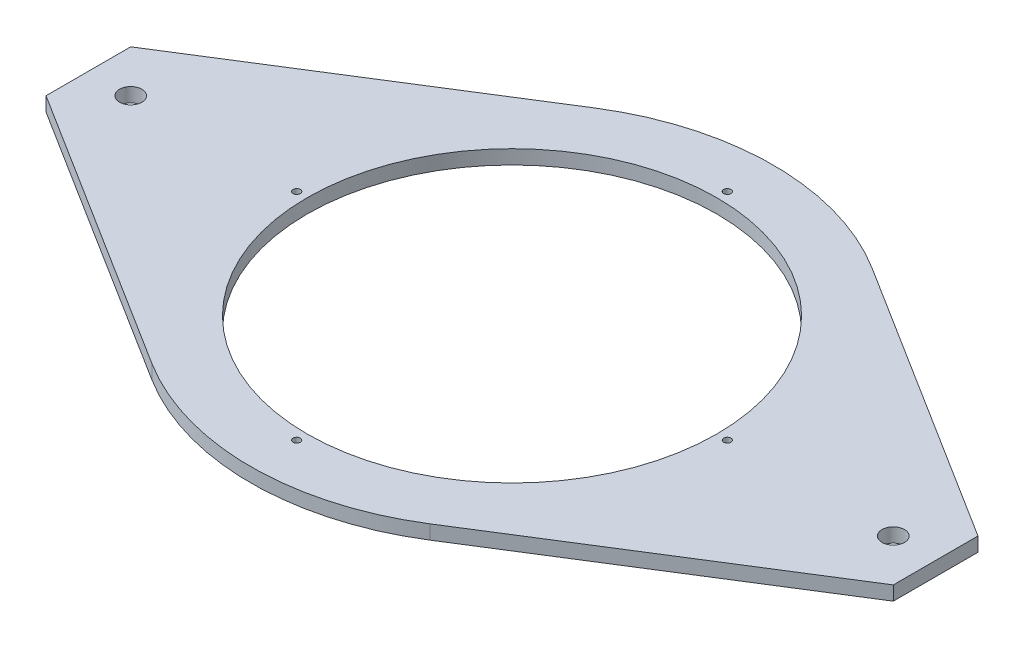
from build123d import *

# Parameters (mm, degrees)
SKETCH1_R               = 92.075
BOSS_EXTRUDE1_DEPTH     = 6.35
F_4_CLEARANCE_HOLE1_D   = 3.2639
F_3_8_CLEARANCE_HOLE1_D = 10.0838


with BuildPart() as part:
    # Sketch1 → Boss-Extrude1 (new body)
    with BuildSketch(Plane(origin=(0, 0, 0), x_dir=(1, 0, 0), z_dir=(0, 1, 0))):
        with BuildLine():
            Line((-190.5, 19.05), (-190.5, -19.05))
            Line((-190.5, -19.05), (-62.495726193, -99.47190474))
            ThreePointArc((-62.495726193, -99.47190474), (0, -117.475), (62.495726193, -99.47190474))
            Line((62.495726193, -99.47190474), (190.5, -19.05))
            Line((190.5, -19.05), (190.5, 19.05))
            Line((190.5, 19.05), (62.495726193, 99.47190474))
            ThreePointArc((62.495726193, 99.47190474), (0, 117.475), (-62.495726193, 99.47190474))
            Line((-62.495726193, 99.47190474), (-190.5, 19.05))
        make_face()
        with Locations(Location((0, 0, 0), (0, 0, 270))):  # turned: the seam where the file's is
            Circle(SKETCH1_R, mode=Mode.SUBTRACT)
    extrude(amount=BOSS_EXTRUDE1_DEPTH)

    # #4 Clearance Hole1 (through all)
    with Locations(Plane(origin=(0, 6.35, 0), x_dir=(1, 0, 0), z_dir=(0, 1, 0))):
        with Locations((0, 96.8375), (96.8375, 0), (0, -96.8375), (-96.8375, 0)):
            Hole(F_4_CLEARANCE_HOLE1_D / 2)

    # 3/8 Clearance Hole1 (through all)
    with Locations(Plane(origin=(0, 6.35, 0), x_dir=(1, 0, 0), z_dir=(0, 1, 0))):
        with Locations((-171.45, 0), (171.45, 0)):
            Hole(F_3_8_CLEARANCE_HOLE1_D / 2)


solid = part.part
